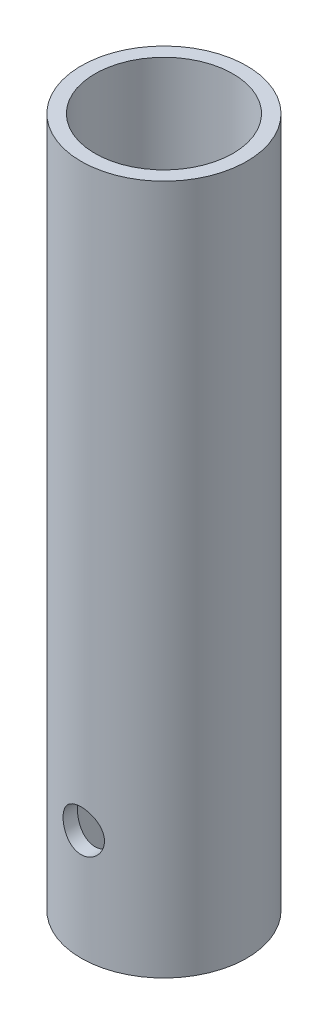
from build123d import *

# Parameters (mm, degrees)
SKETCH1_R               = 6
SKETCH1_R_2             = 5
EXTRUDE_THIN1_DEPTH     = 50
SKETCH2_R               = 1.5
CUT_EXTRUDE1_DEPTH      = 7
CUT_EXTRUDE1_DEPTH_BACK = 7


with BuildPart() as part:
    # Sketch1 → Extrude-Thin1 (new body)
    with BuildSketch(Plane(origin=(0, 0, 0), x_dir=(1, 0, 0), z_dir=(0, 1, 0))):
        Circle(SKETCH1_R)
        Circle(SKETCH1_R_2, mode=Mode.SUBTRACT)
    extrude(amount=EXTRUDE_THIN1_DEPTH)

    # Sketch2 → Cut-Extrude1 (cut, two sides)
    with BuildSketch(Plane.XY) as cut_extrude1_sk:
        with Locations((0, 8)):
            Circle(SKETCH2_R)
    extrude(amount=CUT_EXTRUDE1_DEPTH, mode=Mode.SUBTRACT)
    extrude(cut_extrude1_sk.sketch, amount=-CUT_EXTRUDE1_DEPTH_BACK, mode=Mode.SUBTRACT)


solid = part.part
